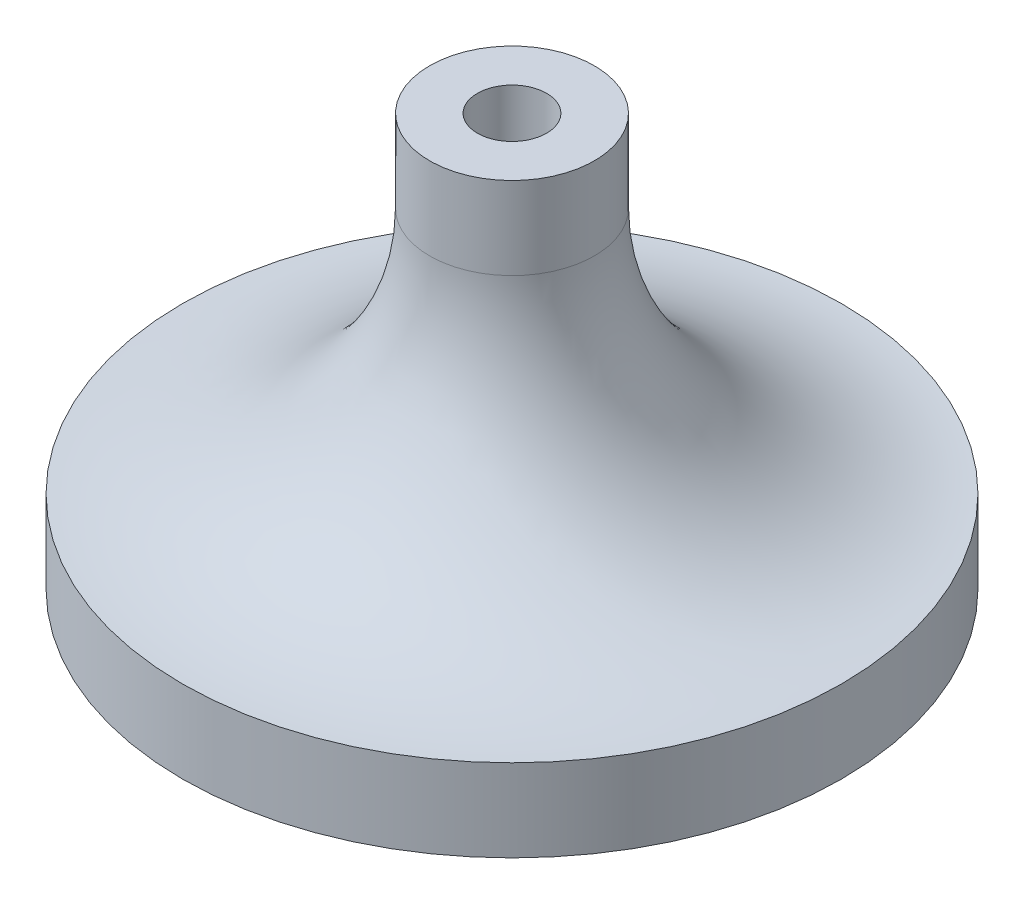
from build123d import *

# Parameters (mm, degrees)
M5X0_8_TAPPED_HOLE1_D     = 4.2
M5X0_8_TAPPED_HOLE1_DEPTH = 19
M5X0_8_TAPPED_HOLE1_TIP   = 1.2618073


with BuildPart() as part:
    # Sketch2 → Revolve1 (revolve)
    with BuildSketch(Plane.XY):
        with BuildLine():
            Line((0, 0), (-20, 0))
            Line((-20, 0), (-20, 5))
            ThreePointArc((-20, 5), (-9.393398282, 9.393398282), (-5, 20))
            Line((-5, 20), (-5, 25))
            Line((-5, 25), (0, 25))
            Line((0, 25), (0, 0))
        make_face()
    revolve(axis=Axis((0, 25, 0), (0, -1, 0)))

    # M5x0.8 Tapped Hole1
    with Locations(Plane(origin=(0, 25, 0), x_dir=(1, 0, 0), z_dir=(0, 1, 0))):
        with Locations((0, 0)):
            Hole(M5X0_8_TAPPED_HOLE1_D / 2, depth=M5X0_8_TAPPED_HOLE1_DEPTH)
            with Locations((0, 0, -(M5X0_8_TAPPED_HOLE1_DEPTH + M5X0_8_TAPPED_HOLE1_TIP / 2))):  # 118° drill point
                Cone(0, M5X0_8_TAPPED_HOLE1_D / 2, M5X0_8_TAPPED_HOLE1_TIP, mode=Mode.SUBTRACT)


solid = part.part
